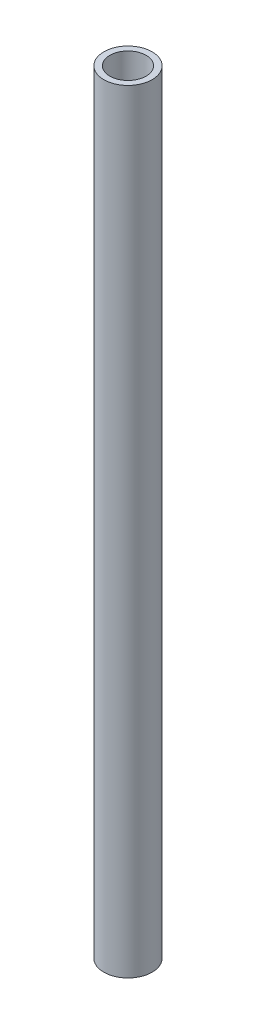
from build123d import *

# Parameters (mm, degrees)
SKETCH1_R           = 12.7
SKETCH1_R_2         = 9.525
BOSS_EXTRUDE2_DEPTH = 406.4


with BuildPart() as part:
    # Sketch1 → Boss-Extrude2 (new body)
    with BuildSketch(Plane(origin=(0, 0, 0), x_dir=(1, 0, 0), z_dir=(0, 1, 0))):
        with Locations((-391.181668083, 212.743279788)):
            Circle(SKETCH1_R)
        with Locations((-391.181668083, 212.743279788)):
            Circle(SKETCH1_R_2, mode=Mode.SUBTRACT)
    extrude(amount=BOSS_EXTRUDE2_DEPTH)


solid = part.part
